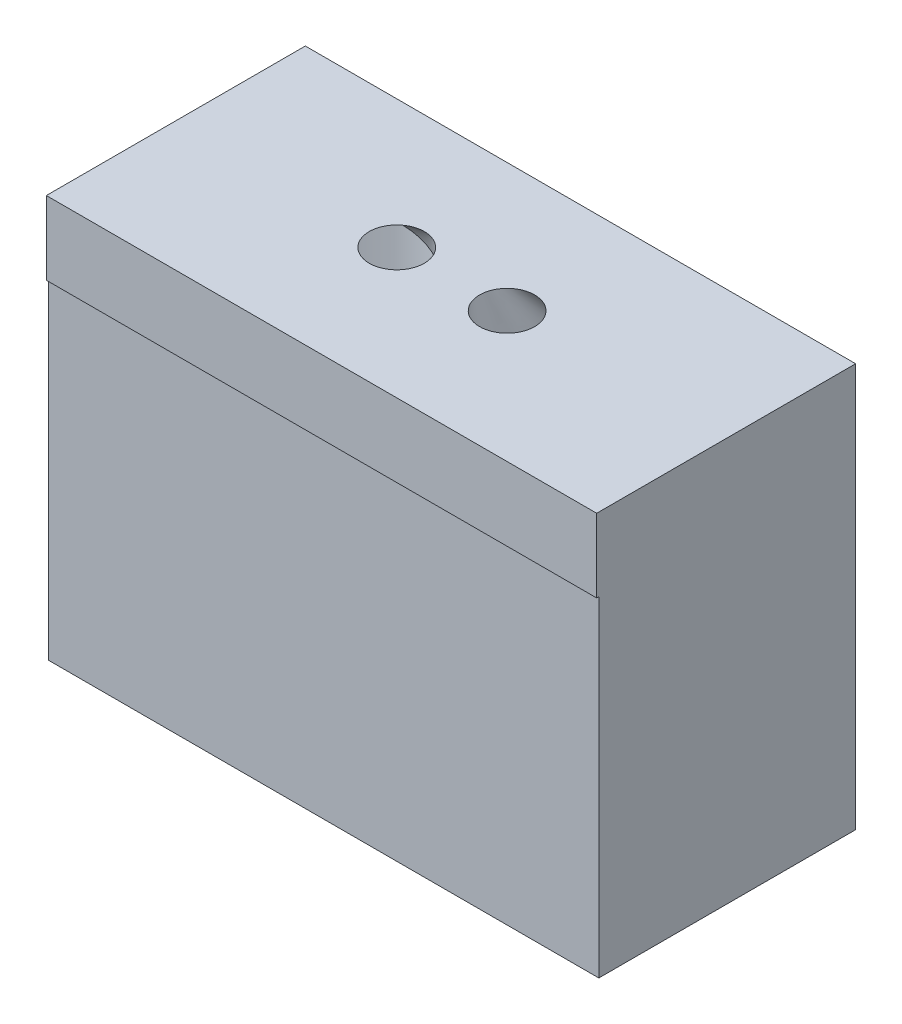
from build123d import *

# Parameters (mm, degrees)
CROQUIS1_W              = 15
CROQUIS1_H              = 7
CROQUIS1_R              = 2.6
SALIENTE_EXTRUIR1_DEPTH = 9
CROQUIS2_R              = 3
CORTAR_EXTRUIR1_DEPTH   = 1
CROQUIS3_W              = 15
CROQUIS3_H              = 7.058739116
SALIENTE_EXTRUIR2_DEPTH = 2
CROQUIS4_R              = 0.75
CROQUIS9_R              = 0.75


with BuildPart() as part:
    # Croquis1 → Saliente-Extruir1 (new body)
    with BuildSketch(Plane(origin=(0, 0, 0), x_dir=(1, 0, 0), z_dir=(0, 1, 0))):
        with Locations((-4, 0)):
            Rectangle(CROQUIS1_W, CROQUIS1_H)
        Circle(CROQUIS1_R, mode=Mode.SUBTRACT)
        with Locations((-8, 0)):
            Circle(CROQUIS1_R, mode=Mode.SUBTRACT)
    extrude(amount=SALIENTE_EXTRUIR1_DEPTH)

    # Croquis2 → Cortar-Extruir1 (cut)
    with BuildSketch(Plane.XZ):
        Circle(CROQUIS2_R)
        with Locations((-8, 0)):
            Circle(CROQUIS2_R)
    extrude(amount=-CORTAR_EXTRUIR1_DEPTH, mode=Mode.SUBTRACT)

    # Croquis3 → Saliente-Extruir2 (add)
    with BuildSketch(Plane(origin=(0, 9, 0), x_dir=(1, 0, 0), z_dir=(0, 1, 0))):
        with Locations((-4, -0.029369558)):
            Rectangle(CROQUIS3_W, CROQUIS3_H)
    extrude(amount=SALIENTE_EXTRUIR2_DEPTH)

    # Croquis4 → section 0 of cortar_recubrir3
    with BuildSketch(Plane(origin=(0, 11, 0), x_dir=(1, 0, 0), z_dir=(0, 1, 0)), mode=Mode.PRIVATE) as cortar_recubrir3_s0:
        with Locations((-5.5, -0.007482418)):
            Circle(CROQUIS4_R)
    # loft up to a face of the part (cortar_recubrir3)
    loft([cortar_recubrir3_s0.sketch, part.faces().sort_by_distance((-8, 9, 0))[0]], mode=Mode.SUBTRACT)

    # Croquis9 → section 0 of cortar_recubrir4
    with BuildSketch(Plane(origin=(0, 11, 0), x_dir=(1, 0, 0), z_dir=(0, 1, 0)), mode=Mode.PRIVATE) as cortar_recubrir4_s0:
        with Locations((-2.5, 0)):
            Circle(CROQUIS9_R)
    # loft up to a face of the part (cortar_recubrir4)
    loft([cortar_recubrir4_s0.sketch, part.faces().sort_by_distance((0, 9, 0))[0]], mode=Mode.SUBTRACT)


solid = part.part
